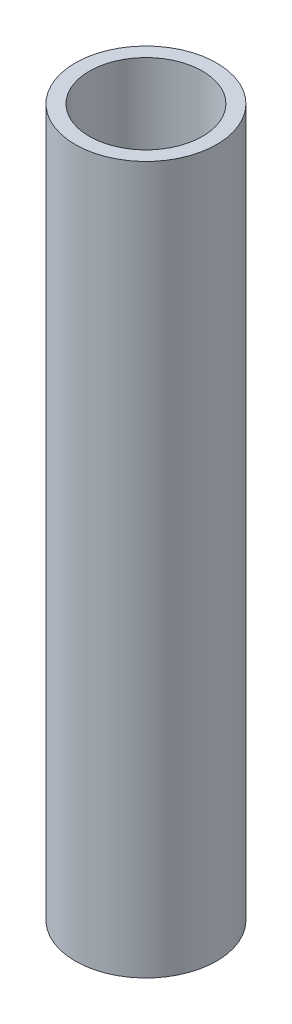
from build123d import *

# Parameters (mm, degrees)
SKETCH1_R           = 5
SKETCH1_R_2         = 4
BOSS_EXTRUDE1_DEPTH = 25


with BuildPart() as part:
    # Sketch1 → Boss-Extrude1 (new body, symmetric)
    with BuildSketch(Plane(origin=(0, 0, 0), x_dir=(1, 0, 0), z_dir=(0, 1, 0))):
        Circle(SKETCH1_R)
        Circle(SKETCH1_R_2, mode=Mode.SUBTRACT)
    extrude(amount=BOSS_EXTRUDE1_DEPTH, both=True)


solid = part.part
